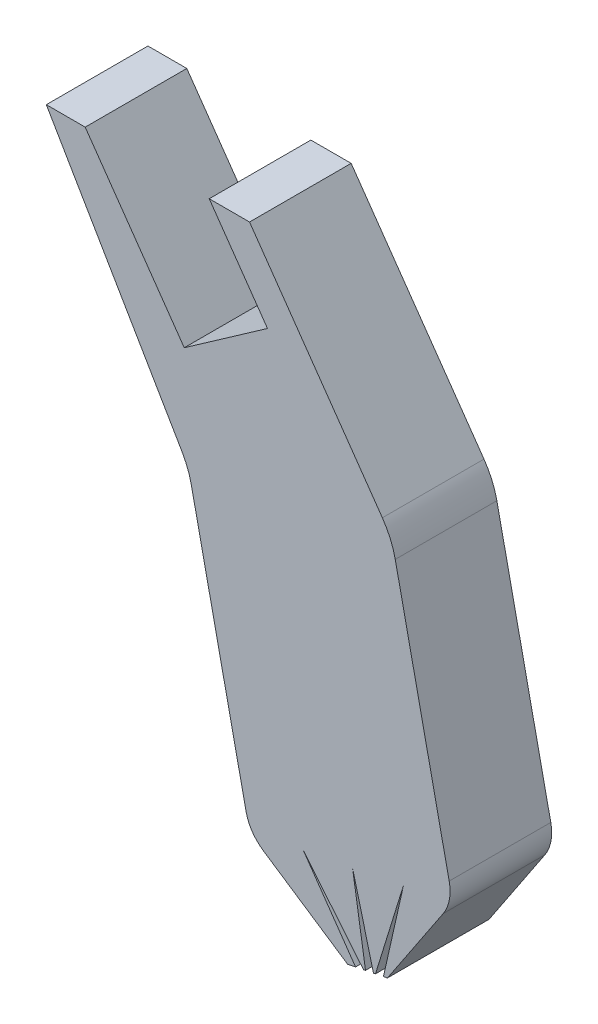
from build123d import *

# Parameters (mm, degrees)
MAIN_EXTRUDE_DEPTH    = 25
BOTTOM_FOOT_CUT_DEPTH = 26
TALON_CUTS_DEPTH      = 26
ANKLE_FILLETS_R       = 10
INNER_LEG_FILLET_R    = 20
KNEE_FILLET_R         = 20
SCALE1_SCALE          = 0.1
CUT_EXTRUDE3_REACH    = 4.5


with BuildPart() as part:
    # Sketch6 → Main Extrude (new body)
    with BuildSketch(Plane.XY):
        Polygon((0, 0), (-50, 0), (-15, -60), (0, -130), (30, -150), (50, -120), (35, -50), align=None)
    extrude(amount=MAIN_EXTRUDE_DEPTH)

    # Sketch9 → Bottom Foot Cut (cut, through all)
    with BuildSketch(Plane(origin=(0, 0, 0), x_dir=(-1, 0, 0), z_dir=(0, 0, -1))):
        Polygon((-30, -150), (-24.116515946, -146.077677297), (-33.922322703, -144.116515946), align=None)
    extrude(amount=-BOTTOM_FOOT_CUT_DEPTH, mode=Mode.SUBTRACT)

    # Sketch11 → Talon Cuts (cut, through all)
    with BuildSketch(Plane(origin=(0, 0, 0), x_dir=(-1, 0, 0), z_dir=(0, 0, -1))):
        Polygon((-32.941742027, -144.312632081), (-30.980580676, -144.704864351), (-37.869672024, -122.426065595), align=None)
        Polygon((-30.490290338, -144.802922419), (-28.529128986, -145.195154689), (-25.342297799, -124.93154044), align=None)
        Polygon((-28.038838649, -145.293212757), (-26.077677297, -145.685445027), (-13.292661468, -127.341467706), align=None)
    extrude(amount=-TALON_CUTS_DEPTH, mode=Mode.SUBTRACT)

    # Ankle Fillets
    ankle_fillets_edges = [part.edges().sort_by_distance(p)[0] for p in [
        (50, -120, 12.5),
        (0, -130, 12.5),
    ]]
    fillet(ankle_fillets_edges, radius=ANKLE_FILLETS_R)

    # Inner Leg Fillet
    inner_leg_fillet_edges = [part.edges().sort_by_distance(p)[0] for p in [
        (-15, -60, 12.5),
    ]]
    fillet(inner_leg_fillet_edges, radius=INNER_LEG_FILLET_R)

    # Knee Fillet
    knee_fillet_edges = [part.edges().sort_by_distance(p)[0] for p in [
        (35, -50, 12.5),
    ]]
    fillet(knee_fillet_edges, radius=KNEE_FILLET_R)


with BuildPart() as part_1:
    # Scale1: scaled about (7.791739568, -67.94361037, 12.5)
    add(part.part.scale(SCALE1_SCALE).moved(Location((7.012565611, -61.149249333, 11.25))))

    # Sketch12 → Cut-Extrude3 (cut, up to next)
    with BuildSketch(Plane(origin=(0, 0, 11.25), x_dir=(-1, 0, 0), z_dir=(0, 0, -1)), mode=Mode.PRIVATE) as cut_extrude3_sk1:
        Polygon((-6.020782968, -61.149249333), (-7.454438828, -63.197329134), (-5.406359027, -64.630984995), (-2.969144064, -61.149249333), align=None)
    cut_extrude3_tool1 = extrude(cut_extrude3_sk1.sketch, amount=-CUT_EXTRUDE3_REACH, mode=Mode.PRIVATE) & part_1.part
    add(cut_extrude3_tool1.solids().sort_by_distance((5.352502, -62.562677, 11.25))[0], mode=Mode.SUBTRACT)


solid = part_1.part
